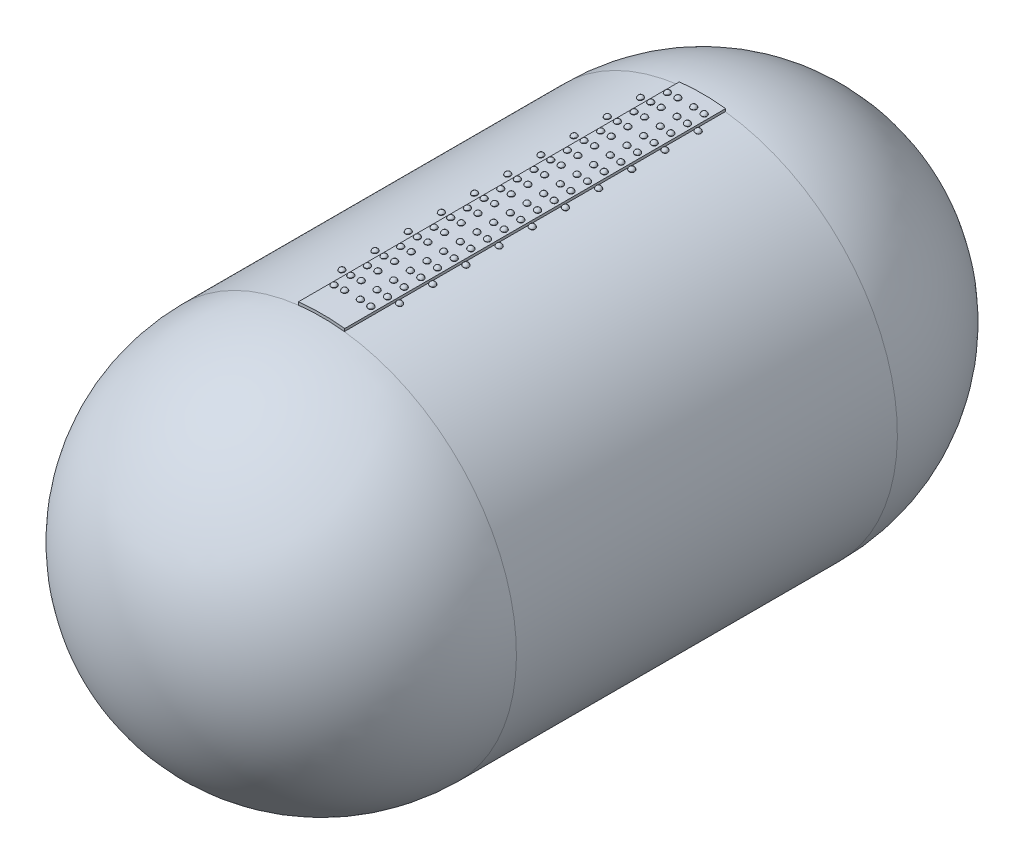
from build123d import *

# Parameters (mm, degrees)
SKETCH1_R           = 1200
BOSS_EXTRUDE1_DEPTH = 2400
LPATTERN1_COUNT     = 21
LPATTERN1_PITCH     = 105
LPATTERN2_COUNT     = 21
LPATTERN2_PITCH     = 105
LPATTERN3_COUNT     = 21
LPATTERN3_PITCH     = 105
LPATTERN4_COUNT     = 21
LPATTERN4_PITCH     = 105
LPATTERN5_COUNT     = 10
LPATTERN5_PITCH     = 209
LPATTERN6_COUNT     = 10
LPATTERN6_PITCH     = 209


with BuildPart() as part:
    # Sketch1 → Boss-Extrude1 (new body)
    with BuildSketch(Plane.XY):
        with BuildLine():
            ThreePointArc((145.831655822, 1237.4365148), (0, 1246), (-145.831655822, 1237.4365148))
            Line((-145.831655822, 1237.4365148), (-143.724938483, 1219.560224859))
            ThreePointArc((-143.724938483, 1219.560224859), (0, -1228), (143.724938483, 1219.560224859))
            Line((143.724938483, 1219.560224859), (145.831655822, 1237.4365148))
        make_face()
        Circle(SKETCH1_R, mode=Mode.SUBTRACT)
    extrude(amount=BOSS_EXTRUDE1_DEPTH)

    # Sketch7 → Revolve3 (revolve)
    with BuildSketch(Plane(origin=(0, 0, 0), x_dir=(0, 0, -1), z_dir=(1, 0, 0))):
        with BuildLine():
            Line((0, 0), (0, -1228))
            ThreePointArc((0, -1228), (868.327127297, -868.327127297), (1228, 0))
            Line((1228, 0), (0, 0))
        make_face()
    revolve3 = revolve(axis=Axis((0, 0, 0), (0, 0, -1)))

    # Mirror2: Revolve3 across plane
    add(revolve3.mirror(Plane.XY.offset(1200)))


with BuildPart() as body_2:
    # Sketch4 → Revolve1 (revolve)
    with BuildSketch(Plane.XY.offset(105)):
        Polygon((-49.486980509, 1245.016882922), (-65.973961704, 1244.361557738), (-68.517483757, 1248.388714994), (-49.650811805, 1249.13862822), align=None)
    revolve(axis=Axis((-49.486980509, 1245.016882922, 105), (0.039716677776448335, -0.999210981478087, 0)))

    # Sketch6 → Revolve2 (revolve)
    with BuildSketch(Plane.XY.offset(105), mode=Mode.PRIVATE) as revolve2_sk:
        with BuildLine():
            Line((-49.650811805, 1249.13862822), (-50.281027197, 1264.993885388))
            ThreePointArc((-50.281027197, 1264.993885388), (-62.424692072, 1260.013954625), (-68.517483757, 1248.388714994))
            Line((-68.517483757, 1248.388714994), (-49.650811805, 1249.13862822))
        make_face()
    revolve(revolve2_sk.sketch.rotate(Axis((-49.650811805, 1249.13862822, 105), (-0.03971667777645193, 0.9992109814780868, 0)), 180), axis=Axis((-49.650811805, 1249.13862822, 105), (-0.03971667777645193, 0.9992109814780868, 0)))


with BuildPart() as body_3:
    # Mirror1: mirrored copy
    add(body_2.part.mirror(Plane(origin=(0, 0, 0), x_dir=(0, 0, 1), z_dir=(1, 0, 0))))


with BuildPart() as lpattern1_1:
    # LPattern1: pattern copy
    add(body_2.part.moved(Location(Vector(0, 0, 1) * (1 * LPATTERN1_PITCH))))


with BuildPart() as lpattern1_2:
    # LPattern1: pattern copy
    add(body_2.part.moved(Location(Vector(0, 0, 1) * (2 * LPATTERN1_PITCH))))


with BuildPart() as lpattern1_3:
    # LPattern1: pattern copy
    add(body_2.part.moved(Location(Vector(0, 0, 1) * (3 * LPATTERN1_PITCH))))


with BuildPart() as lpattern1_4:
    # LPattern1: pattern copy
    add(body_2.part.moved(Location(Vector(0, 0, 1) * (4 * LPATTERN1_PITCH))))


with BuildPart() as lpattern1_5:
    # LPattern1: pattern copy
    add(body_2.part.moved(Location(Vector(0, 0, 1) * (5 * LPATTERN1_PITCH))))


with BuildPart() as lpattern1_6:
    # LPattern1: pattern copy
    add(body_2.part.moved(Location(Vector(0, 0, 1) * (6 * LPATTERN1_PITCH))))


with BuildPart() as lpattern1_7:
    # LPattern1: pattern copy
    add(body_2.part.moved(Location(Vector(0, 0, 1) * (7 * LPATTERN1_PITCH))))


with BuildPart() as lpattern1_8:
    # LPattern1: pattern copy
    add(body_2.part.moved(Location(Vector(0, 0, 1) * (8 * LPATTERN1_PITCH))))


with BuildPart() as lpattern1_9:
    # LPattern1: pattern copy
    add(body_2.part.moved(Location(Vector(0, 0, 1) * (9 * LPATTERN1_PITCH))))


with BuildPart() as lpattern1_10:
    # LPattern1: pattern copy
    add(body_2.part.moved(Location(Vector(0, 0, 1) * (10 * LPATTERN1_PITCH))))


with BuildPart() as lpattern1_11:
    # LPattern1: pattern copy
    add(body_2.part.moved(Location(Vector(0, 0, 1) * (11 * LPATTERN1_PITCH))))


with BuildPart() as lpattern1_12:
    # LPattern1: pattern copy
    add(body_2.part.moved(Location(Vector(0, 0, 1) * (12 * LPATTERN1_PITCH))))


with BuildPart() as lpattern1_13:
    # LPattern1: pattern copy
    add(body_2.part.moved(Location(Vector(0, 0, 1) * (13 * LPATTERN1_PITCH))))


with BuildPart() as lpattern1_14:
    # LPattern1: pattern copy
    add(body_2.part.moved(Location(Vector(0, 0, 1) * (14 * LPATTERN1_PITCH))))


with BuildPart() as lpattern1_15:
    # LPattern1: pattern copy
    add(body_2.part.moved(Location(Vector(0, 0, 1) * (15 * LPATTERN1_PITCH))))


with BuildPart() as lpattern1_16:
    # LPattern1: pattern copy
    add(body_2.part.moved(Location(Vector(0, 0, 1) * (16 * LPATTERN1_PITCH))))


with BuildPart() as lpattern1_17:
    # LPattern1: pattern copy
    add(body_2.part.moved(Location(Vector(0, 0, 1) * (17 * LPATTERN1_PITCH))))


with BuildPart() as lpattern1_18:
    # LPattern1: pattern copy
    add(body_2.part.moved(Location(Vector(0, 0, 1) * (18 * LPATTERN1_PITCH))))


with BuildPart() as lpattern1_19:
    # LPattern1: pattern copy
    add(body_2.part.moved(Location(Vector(0, 0, 1) * (19 * LPATTERN1_PITCH))))


with BuildPart() as lpattern1_20:
    # LPattern1: pattern copy
    add(body_2.part.moved(Location(Vector(0, 0, 1) * (20 * LPATTERN1_PITCH))))


with BuildPart() as lpattern2_1:
    # LPattern2: pattern copy
    add(body_3.part.moved(Location(Vector(0, 0, 1) * (1 * LPATTERN2_PITCH))))


with BuildPart() as lpattern2_2:
    # LPattern2: pattern copy
    add(body_3.part.moved(Location(Vector(0, 0, 1) * (2 * LPATTERN2_PITCH))))


with BuildPart() as lpattern2_3:
    # LPattern2: pattern copy
    add(body_3.part.moved(Location(Vector(0, 0, 1) * (3 * LPATTERN2_PITCH))))


with BuildPart() as lpattern2_4:
    # LPattern2: pattern copy
    add(body_3.part.moved(Location(Vector(0, 0, 1) * (4 * LPATTERN2_PITCH))))


with BuildPart() as lpattern2_5:
    # LPattern2: pattern copy
    add(body_3.part.moved(Location(Vector(0, 0, 1) * (5 * LPATTERN2_PITCH))))


with BuildPart() as lpattern2_6:
    # LPattern2: pattern copy
    add(body_3.part.moved(Location(Vector(0, 0, 1) * (6 * LPATTERN2_PITCH))))


with BuildPart() as lpattern2_7:
    # LPattern2: pattern copy
    add(body_3.part.moved(Location(Vector(0, 0, 1) * (7 * LPATTERN2_PITCH))))


with BuildPart() as lpattern2_8:
    # LPattern2: pattern copy
    add(body_3.part.moved(Location(Vector(0, 0, 1) * (8 * LPATTERN2_PITCH))))


with BuildPart() as lpattern2_9:
    # LPattern2: pattern copy
    add(body_3.part.moved(Location(Vector(0, 0, 1) * (9 * LPATTERN2_PITCH))))


with BuildPart() as lpattern2_10:
    # LPattern2: pattern copy
    add(body_3.part.moved(Location(Vector(0, 0, 1) * (10 * LPATTERN2_PITCH))))


with BuildPart() as lpattern2_11:
    # LPattern2: pattern copy
    add(body_3.part.moved(Location(Vector(0, 0, 1) * (11 * LPATTERN2_PITCH))))


with BuildPart() as lpattern2_12:
    # LPattern2: pattern copy
    add(body_3.part.moved(Location(Vector(0, 0, 1) * (12 * LPATTERN2_PITCH))))


with BuildPart() as lpattern2_13:
    # LPattern2: pattern copy
    add(body_3.part.moved(Location(Vector(0, 0, 1) * (13 * LPATTERN2_PITCH))))


with BuildPart() as lpattern2_14:
    # LPattern2: pattern copy
    add(body_3.part.moved(Location(Vector(0, 0, 1) * (14 * LPATTERN2_PITCH))))


with BuildPart() as lpattern2_15:
    # LPattern2: pattern copy
    add(body_3.part.moved(Location(Vector(0, 0, 1) * (15 * LPATTERN2_PITCH))))


with BuildPart() as lpattern2_16:
    # LPattern2: pattern copy
    add(body_3.part.moved(Location(Vector(0, 0, 1) * (16 * LPATTERN2_PITCH))))


with BuildPart() as lpattern2_17:
    # LPattern2: pattern copy
    add(body_3.part.moved(Location(Vector(0, 0, 1) * (17 * LPATTERN2_PITCH))))


with BuildPart() as lpattern2_18:
    # LPattern2: pattern copy
    add(body_3.part.moved(Location(Vector(0, 0, 1) * (18 * LPATTERN2_PITCH))))


with BuildPart() as lpattern2_19:
    # LPattern2: pattern copy
    add(body_3.part.moved(Location(Vector(0, 0, 1) * (19 * LPATTERN2_PITCH))))


with BuildPart() as lpattern2_20:
    # LPattern2: pattern copy
    add(body_3.part.moved(Location(Vector(0, 0, 1) * (20 * LPATTERN2_PITCH))))


with BuildPart() as body_44:
    # Sketch9 → Revolve4 (revolve)
    with BuildSketch(Plane.XY.offset(105), mode=Mode.PRIVATE) as revolve4_sk:
        Polygon((115.334662248, 1240.650601775), (98.905500989, 1242.177906692), (96.915982049, 1246.505644483), (115.716488477, 1244.75789209), align=None)
    revolve(revolve4_sk.sketch.rotate(Axis((115.334662248, 1240.650601775, 105), (0.09256393438849174, 0.9957067429974165, 0)), 180), axis=Axis((115.334662248, 1240.650601775, 105), (0.09256393438849174, 0.9957067429974165, 0)))

    # Sketch11 → Revolve5 (revolve)
    with BuildSketch(Plane.XY.offset(105)):
        with BuildLine():
            Line((115.716488477, 1244.75789209), (117.185272359, 1260.557544782))
            ThreePointArc((117.185272359, 1260.557544782), (104.490392508, 1257.22462826), (96.915982049, 1246.505644483))
            Line((96.915982049, 1246.505644483), (115.716488477, 1244.75789209))
        make_face()
    revolve(axis=Axis((115.716488477, 1244.75789209, 105), (0.09256393438847273, 0.9957067429974182, 0)))


with BuildPart() as body_45:
    # Mirror3: mirrored copy
    add(body_44.part.mirror(Plane(origin=(0, 0, 0), x_dir=(0, 0, 1), z_dir=(1, 0, 0))))


with BuildPart() as lpattern3_1:
    # LPattern3: pattern copy
    add(body_44.part.moved(Location(Vector(0, 0, 1) * (1 * LPATTERN3_PITCH))))


with BuildPart() as lpattern3_2:
    # LPattern3: pattern copy
    add(body_44.part.moved(Location(Vector(0, 0, 1) * (2 * LPATTERN3_PITCH))))


with BuildPart() as lpattern3_3:
    # LPattern3: pattern copy
    add(body_44.part.moved(Location(Vector(0, 0, 1) * (3 * LPATTERN3_PITCH))))


with BuildPart() as lpattern3_4:
    # LPattern3: pattern copy
    add(body_44.part.moved(Location(Vector(0, 0, 1) * (4 * LPATTERN3_PITCH))))


with BuildPart() as lpattern3_5:
    # LPattern3: pattern copy
    add(body_44.part.moved(Location(Vector(0, 0, 1) * (5 * LPATTERN3_PITCH))))


with BuildPart() as lpattern3_6:
    # LPattern3: pattern copy
    add(body_44.part.moved(Location(Vector(0, 0, 1) * (6 * LPATTERN3_PITCH))))


with BuildPart() as lpattern3_7:
    # LPattern3: pattern copy
    add(body_44.part.moved(Location(Vector(0, 0, 1) * (7 * LPATTERN3_PITCH))))


with BuildPart() as lpattern3_8:
    # LPattern3: pattern copy
    add(body_44.part.moved(Location(Vector(0, 0, 1) * (8 * LPATTERN3_PITCH))))


with BuildPart() as lpattern3_9:
    # LPattern3: pattern copy
    add(body_44.part.moved(Location(Vector(0, 0, 1) * (9 * LPATTERN3_PITCH))))


with BuildPart() as lpattern3_10:
    # LPattern3: pattern copy
    add(body_44.part.moved(Location(Vector(0, 0, 1) * (10 * LPATTERN3_PITCH))))


with BuildPart() as lpattern3_11:
    # LPattern3: pattern copy
    add(body_44.part.moved(Location(Vector(0, 0, 1) * (11 * LPATTERN3_PITCH))))


with BuildPart() as lpattern3_12:
    # LPattern3: pattern copy
    add(body_44.part.moved(Location(Vector(0, 0, 1) * (12 * LPATTERN3_PITCH))))


with BuildPart() as lpattern3_13:
    # LPattern3: pattern copy
    add(body_44.part.moved(Location(Vector(0, 0, 1) * (13 * LPATTERN3_PITCH))))


with BuildPart() as lpattern3_14:
    # LPattern3: pattern copy
    add(body_44.part.moved(Location(Vector(0, 0, 1) * (14 * LPATTERN3_PITCH))))


with BuildPart() as lpattern3_15:
    # LPattern3: pattern copy
    add(body_44.part.moved(Location(Vector(0, 0, 1) * (15 * LPATTERN3_PITCH))))


with BuildPart() as lpattern3_16:
    # LPattern3: pattern copy
    add(body_44.part.moved(Location(Vector(0, 0, 1) * (16 * LPATTERN3_PITCH))))


with BuildPart() as lpattern3_17:
    # LPattern3: pattern copy
    add(body_44.part.moved(Location(Vector(0, 0, 1) * (17 * LPATTERN3_PITCH))))


with BuildPart() as lpattern3_18:
    # LPattern3: pattern copy
    add(body_44.part.moved(Location(Vector(0, 0, 1) * (18 * LPATTERN3_PITCH))))


with BuildPart() as lpattern3_19:
    # LPattern3: pattern copy
    add(body_44.part.moved(Location(Vector(0, 0, 1) * (19 * LPATTERN3_PITCH))))


with BuildPart() as lpattern3_20:
    # LPattern3: pattern copy
    add(body_44.part.moved(Location(Vector(0, 0, 1) * (20 * LPATTERN3_PITCH))))


with BuildPart() as lpattern4_1:
    # LPattern4: pattern copy
    add(body_45.part.moved(Location(Vector(0, 0, 1) * (1 * LPATTERN4_PITCH))))


with BuildPart() as lpattern4_2:
    # LPattern4: pattern copy
    add(body_45.part.moved(Location(Vector(0, 0, 1) * (2 * LPATTERN4_PITCH))))


with BuildPart() as lpattern4_3:
    # LPattern4: pattern copy
    add(body_45.part.moved(Location(Vector(0, 0, 1) * (3 * LPATTERN4_PITCH))))


with BuildPart() as lpattern4_4:
    # LPattern4: pattern copy
    add(body_45.part.moved(Location(Vector(0, 0, 1) * (4 * LPATTERN4_PITCH))))


with BuildPart() as lpattern4_5:
    # LPattern4: pattern copy
    add(body_45.part.moved(Location(Vector(0, 0, 1) * (5 * LPATTERN4_PITCH))))


with BuildPart() as lpattern4_6:
    # LPattern4: pattern copy
    add(body_45.part.moved(Location(Vector(0, 0, 1) * (6 * LPATTERN4_PITCH))))


with BuildPart() as lpattern4_7:
    # LPattern4: pattern copy
    add(body_45.part.moved(Location(Vector(0, 0, 1) * (7 * LPATTERN4_PITCH))))


with BuildPart() as lpattern4_8:
    # LPattern4: pattern copy
    add(body_45.part.moved(Location(Vector(0, 0, 1) * (8 * LPATTERN4_PITCH))))


with BuildPart() as lpattern4_9:
    # LPattern4: pattern copy
    add(body_45.part.moved(Location(Vector(0, 0, 1) * (9 * LPATTERN4_PITCH))))


with BuildPart() as lpattern4_10:
    # LPattern4: pattern copy
    add(body_45.part.moved(Location(Vector(0, 0, 1) * (10 * LPATTERN4_PITCH))))


with BuildPart() as lpattern4_11:
    # LPattern4: pattern copy
    add(body_45.part.moved(Location(Vector(0, 0, 1) * (11 * LPATTERN4_PITCH))))


with BuildPart() as lpattern4_12:
    # LPattern4: pattern copy
    add(body_45.part.moved(Location(Vector(0, 0, 1) * (12 * LPATTERN4_PITCH))))


with BuildPart() as lpattern4_13:
    # LPattern4: pattern copy
    add(body_45.part.moved(Location(Vector(0, 0, 1) * (13 * LPATTERN4_PITCH))))


with BuildPart() as lpattern4_14:
    # LPattern4: pattern copy
    add(body_45.part.moved(Location(Vector(0, 0, 1) * (14 * LPATTERN4_PITCH))))


with BuildPart() as lpattern4_15:
    # LPattern4: pattern copy
    add(body_45.part.moved(Location(Vector(0, 0, 1) * (15 * LPATTERN4_PITCH))))


with BuildPart() as lpattern4_16:
    # LPattern4: pattern copy
    add(body_45.part.moved(Location(Vector(0, 0, 1) * (16 * LPATTERN4_PITCH))))


with BuildPart() as lpattern4_17:
    # LPattern4: pattern copy
    add(body_45.part.moved(Location(Vector(0, 0, 1) * (17 * LPATTERN4_PITCH))))


with BuildPart() as lpattern4_18:
    # LPattern4: pattern copy
    add(body_45.part.moved(Location(Vector(0, 0, 1) * (18 * LPATTERN4_PITCH))))


with BuildPart() as lpattern4_19:
    # LPattern4: pattern copy
    add(body_45.part.moved(Location(Vector(0, 0, 1) * (19 * LPATTERN4_PITCH))))


with BuildPart() as lpattern4_20:
    # LPattern4: pattern copy
    add(body_45.part.moved(Location(Vector(0, 0, 1) * (20 * LPATTERN4_PITCH))))


with BuildPart() as body_86:
    # Sketch16 → Revolve6 (revolve)
    with BuildSketch(Plane.XY.offset(209)):
        Polygon((180.858817316, 1232.804156466), (164.533561633, 1235.199156855), (162.775964039, 1239.626159306), (181.457567414, 1236.885470387), align=None)
    revolve(axis=Axis((181.457567414, 1236.885470387, 209), (-0.14515153877701675, -0.9894094353656955, 0)))


with BuildPart() as body_87:
    # Sketch17 → Revolve7 (revolve)
    with BuildSketch(Plane.XY.offset(209), mode=Mode.PRIVATE) as revolve7_sk:
        with BuildLine():
            Line((183.760799682, 1252.585198805), (181.457567414, 1236.885470387))
            Line((181.457567414, 1236.885470387), (162.775964039, 1239.626159306))
            ThreePointArc((162.775964039, 1239.626159306), (170.907264727, 1249.929083945), (183.760799682, 1252.585198805))
        make_face()
    revolve(revolve7_sk.sketch.rotate(Axis((0, 0, 209), (0.1451515387771252, 0.9894094353656795, 0)), 180), axis=Axis((0, 0, 209), (0.1451515387771252, 0.9894094353656795, 0)))


with BuildPart() as body_88:
    # Mirror4: mirrored copy
    add(body_87.part.mirror(Plane(origin=(0, 0, 0), x_dir=(0, 0, 1), z_dir=(1, 0, 0))))


with BuildPart() as body_89:
    # Mirror4 2: mirrored copy
    add(body_86.part.mirror(Plane(origin=(0, 0, 0), x_dir=(0, 0, 1), z_dir=(1, 0, 0))))


with BuildPart() as lpattern5_1:
    # LPattern5: pattern copy
    add(body_86.part.moved(Location(Vector(0, 0, 1) * (1 * LPATTERN5_PITCH))))


with BuildPart() as lpattern5_2:
    # LPattern5: pattern copy
    add(body_86.part.moved(Location(Vector(0, 0, 1) * (2 * LPATTERN5_PITCH))))


with BuildPart() as lpattern5_3:
    # LPattern5: pattern copy
    add(body_86.part.moved(Location(Vector(0, 0, 1) * (3 * LPATTERN5_PITCH))))


with BuildPart() as lpattern5_4:
    # LPattern5: pattern copy
    add(body_86.part.moved(Location(Vector(0, 0, 1) * (4 * LPATTERN5_PITCH))))


with BuildPart() as lpattern5_5:
    # LPattern5: pattern copy
    add(body_86.part.moved(Location(Vector(0, 0, 1) * (5 * LPATTERN5_PITCH))))


with BuildPart() as lpattern5_6:
    # LPattern5: pattern copy
    add(body_86.part.moved(Location(Vector(0, 0, 1) * (6 * LPATTERN5_PITCH))))


with BuildPart() as lpattern5_7:
    # LPattern5: pattern copy
    add(body_86.part.moved(Location(Vector(0, 0, 1) * (7 * LPATTERN5_PITCH))))


with BuildPart() as lpattern5_8:
    # LPattern5: pattern copy
    add(body_86.part.moved(Location(Vector(0, 0, 1) * (8 * LPATTERN5_PITCH))))


with BuildPart() as lpattern5_9:
    # LPattern5: pattern copy
    add(body_86.part.moved(Location(Vector(0, 0, 1) * (9 * LPATTERN5_PITCH))))


with BuildPart() as lpattern5_10:
    # LPattern5: pattern copy
    add(body_87.part.moved(Location(Vector(0, 0, 1) * (1 * LPATTERN5_PITCH))))


with BuildPart() as lpattern5_11:
    # LPattern5: pattern copy
    add(body_87.part.moved(Location(Vector(0, 0, 1) * (2 * LPATTERN5_PITCH))))


with BuildPart() as lpattern5_12:
    # LPattern5: pattern copy
    add(body_87.part.moved(Location(Vector(0, 0, 1) * (3 * LPATTERN5_PITCH))))


with BuildPart() as lpattern5_13:
    # LPattern5: pattern copy
    add(body_87.part.moved(Location(Vector(0, 0, 1) * (4 * LPATTERN5_PITCH))))


with BuildPart() as lpattern5_14:
    # LPattern5: pattern copy
    add(body_87.part.moved(Location(Vector(0, 0, 1) * (5 * LPATTERN5_PITCH))))


with BuildPart() as lpattern5_15:
    # LPattern5: pattern copy
    add(body_87.part.moved(Location(Vector(0, 0, 1) * (6 * LPATTERN5_PITCH))))


with BuildPart() as lpattern5_16:
    # LPattern5: pattern copy
    add(body_87.part.moved(Location(Vector(0, 0, 1) * (7 * LPATTERN5_PITCH))))


with BuildPart() as lpattern5_17:
    # LPattern5: pattern copy
    add(body_87.part.moved(Location(Vector(0, 0, 1) * (8 * LPATTERN5_PITCH))))


with BuildPart() as lpattern5_18:
    # LPattern5: pattern copy
    add(body_87.part.moved(Location(Vector(0, 0, 1) * (9 * LPATTERN5_PITCH))))


with BuildPart() as lpattern6_1:
    # LPattern6: pattern copy
    add(body_89.part.moved(Location(Vector(0, 0, 1) * (1 * LPATTERN6_PITCH))))


with BuildPart() as lpattern6_2:
    # LPattern6: pattern copy
    add(body_89.part.moved(Location(Vector(0, 0, 1) * (2 * LPATTERN6_PITCH))))


with BuildPart() as lpattern6_3:
    # LPattern6: pattern copy
    add(body_89.part.moved(Location(Vector(0, 0, 1) * (3 * LPATTERN6_PITCH))))


with BuildPart() as lpattern6_4:
    # LPattern6: pattern copy
    add(body_89.part.moved(Location(Vector(0, 0, 1) * (4 * LPATTERN6_PITCH))))


with BuildPart() as lpattern6_5:
    # LPattern6: pattern copy
    add(body_89.part.moved(Location(Vector(0, 0, 1) * (5 * LPATTERN6_PITCH))))


with BuildPart() as lpattern6_6:
    # LPattern6: pattern copy
    add(body_89.part.moved(Location(Vector(0, 0, 1) * (6 * LPATTERN6_PITCH))))


with BuildPart() as lpattern6_7:
    # LPattern6: pattern copy
    add(body_89.part.moved(Location(Vector(0, 0, 1) * (7 * LPATTERN6_PITCH))))


with BuildPart() as lpattern6_8:
    # LPattern6: pattern copy
    add(body_89.part.moved(Location(Vector(0, 0, 1) * (8 * LPATTERN6_PITCH))))


with BuildPart() as lpattern6_9:
    # LPattern6: pattern copy
    add(body_89.part.moved(Location(Vector(0, 0, 1) * (9 * LPATTERN6_PITCH))))


with BuildPart() as lpattern6_10:
    # LPattern6: pattern copy
    add(body_88.part.moved(Location(Vector(0, 0, 1) * (1 * LPATTERN6_PITCH))))


with BuildPart() as lpattern6_11:
    # LPattern6: pattern copy
    add(body_88.part.moved(Location(Vector(0, 0, 1) * (2 * LPATTERN6_PITCH))))


with BuildPart() as lpattern6_12:
    # LPattern6: pattern copy
    add(body_88.part.moved(Location(Vector(0, 0, 1) * (3 * LPATTERN6_PITCH))))


with BuildPart() as lpattern6_13:
    # LPattern6: pattern copy
    add(body_88.part.moved(Location(Vector(0, 0, 1) * (4 * LPATTERN6_PITCH))))


with BuildPart() as lpattern6_14:
    # LPattern6: pattern copy
    add(body_88.part.moved(Location(Vector(0, 0, 1) * (5 * LPATTERN6_PITCH))))


with BuildPart() as lpattern6_15:
    # LPattern6: pattern copy
    add(body_88.part.moved(Location(Vector(0, 0, 1) * (6 * LPATTERN6_PITCH))))


with BuildPart() as lpattern6_16:
    # LPattern6: pattern copy
    add(body_88.part.moved(Location(Vector(0, 0, 1) * (7 * LPATTERN6_PITCH))))


with BuildPart() as lpattern6_17:
    # LPattern6: pattern copy
    add(body_88.part.moved(Location(Vector(0, 0, 1) * (8 * LPATTERN6_PITCH))))


with BuildPart() as lpattern6_18:
    # LPattern6: pattern copy
    add(body_88.part.moved(Location(Vector(0, 0, 1) * (9 * LPATTERN6_PITCH))))


solid = Compound([part.part, body_2.part, body_3.part, lpattern1_1.part, lpattern1_2.part, lpattern1_3.part, lpattern1_4.part, lpattern1_5.part, lpattern1_6.part, lpattern1_7.part, lpattern1_8.part, lpattern1_9.part, lpattern1_10.part, lpattern1_11.part, lpattern1_12.part, lpattern1_13.part, lpattern1_14.part, lpattern1_15.part, lpattern1_16.part, lpattern1_17.part, lpattern1_18.part, lpattern1_19.part, lpattern1_20.part, lpattern2_1.part, lpattern2_2.part, lpattern2_3.part, lpattern2_4.part, lpattern2_5.part, lpattern2_6.part, lpattern2_7.part, lpattern2_8.part, lpattern2_9.part, lpattern2_10.part, lpattern2_11.part, lpattern2_12.part, lpattern2_13.part, lpattern2_14.part, lpattern2_15.part, lpattern2_16.part, lpattern2_17.part, lpattern2_18.part, lpattern2_19.part, lpattern2_20.part, body_44.part, body_45.part, lpattern3_1.part, lpattern3_2.part, lpattern3_3.part, lpattern3_4.part, lpattern3_5.part, lpattern3_6.part, lpattern3_7.part, lpattern3_8.part, lpattern3_9.part, lpattern3_10.part, lpattern3_11.part, lpattern3_12.part, lpattern3_13.part, lpattern3_14.part, lpattern3_15.part, lpattern3_16.part, lpattern3_17.part, lpattern3_18.part, lpattern3_19.part, lpattern3_20.part, lpattern4_1.part, lpattern4_2.part, lpattern4_3.part, lpattern4_4.part, lpattern4_5.part, lpattern4_6.part, lpattern4_7.part, lpattern4_8.part, lpattern4_9.part, lpattern4_10.part, lpattern4_11.part, lpattern4_12.part, lpattern4_13.part, lpattern4_14.part, lpattern4_15.part, lpattern4_16.part, lpattern4_17.part, lpattern4_18.part, lpattern4_19.part, lpattern4_20.part, body_86.part, body_87.part, body_88.part, body_89.part, lpattern5_1.part, lpattern5_2.part, lpattern5_3.part, lpattern5_4.part, lpattern5_5.part, lpattern5_6.part, lpattern5_7.part, lpattern5_8.part, lpattern5_9.part, lpattern5_10.part, lpattern5_11.part, lpattern5_12.part, lpattern5_13.part, lpattern5_14.part, lpattern5_15.part, lpattern5_16.part, lpattern5_17.part, lpattern5_18.part, lpattern6_1.part, lpattern6_2.part, lpattern6_3.part, lpattern6_4.part, lpattern6_5.part, lpattern6_6.part, lpattern6_7.part, lpattern6_8.part, lpattern6_9.part, lpattern6_10.part, lpattern6_11.part, lpattern6_12.part, lpattern6_13.part, lpattern6_14.part, lpattern6_15.part, lpattern6_16.part, lpattern6_17.part, lpattern6_18.part])
